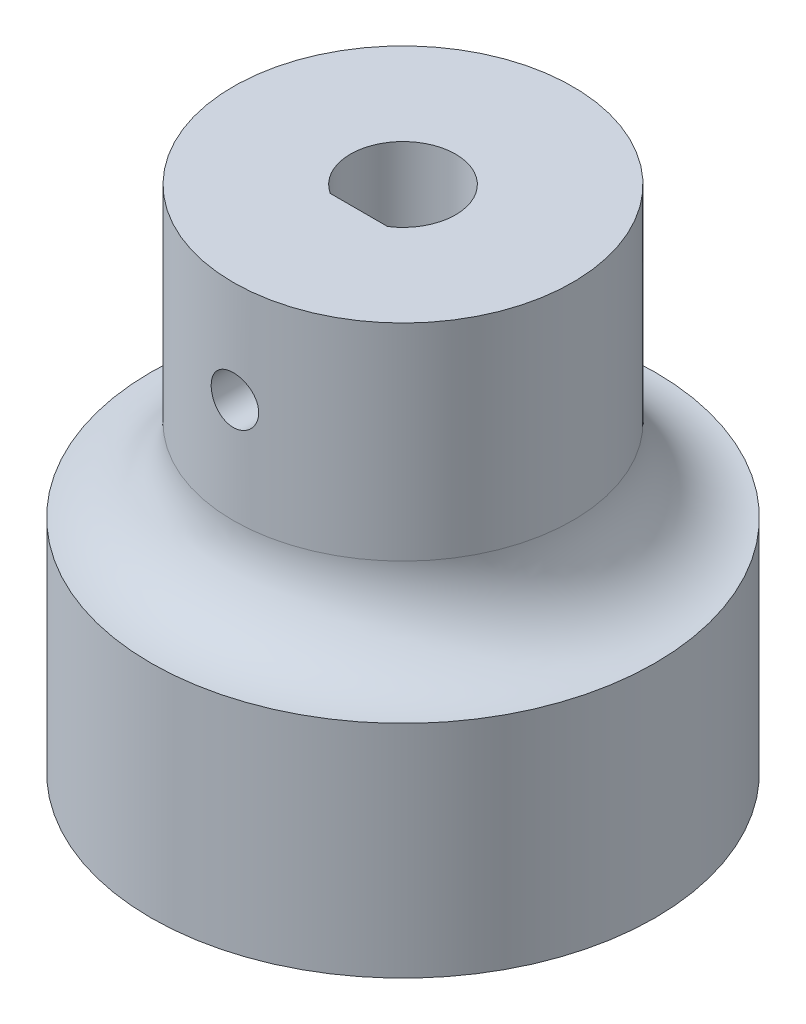
from build123d import *

# Parameters (mm, degrees)
SKETCH_1_R          = 14.85
EXTRUDE_1_DEPTH     = 13
SKETCH_2_R          = 10
EXTRUDE_2_DEPTH     = 17
CUT_EXTRUDE_1_DEPTH = 12
SKETCH_13_R         = 1.4
CUT_EXTRUDE_2_DEPTH = 13.25


with BuildPart() as part:
    # 스케치1 → 보스-돌출1 (new body)
    with BuildSketch(Plane(origin=(0, 0, 0), x_dir=(1, 0, 0), z_dir=(0, 1, 0))):
        Circle(SKETCH_1_R)
    extrude(amount=EXTRUDE_1_DEPTH)

    # 스케치2 → 보스-돌출2 (add)
    with BuildSketch(Plane(origin=(0, 13, 0), x_dir=(1, 0, 0), z_dir=(0, 1, 0))):
        Circle(SKETCH_2_R)
    extrude(amount=EXTRUDE_2_DEPTH)

    # 스케치4 → 컷-돌출1 (cut)
    with BuildSketch(Plane(origin=(0, 30, 0), x_dir=(1, 0, 0), z_dir=(0, 1, 0))):
        with BuildLine():
            Line((-1.688194302, -2.6), (1.688194302, -2.6))
            ThreePointArc((1.688194302, -2.6), (0, 3.1), (-1.688194302, -2.6))
        make_face()
    extrude(amount=-CUT_EXTRUDE_1_DEPTH, mode=Mode.SUBTRACT)

    # 스케치13 → 컷-돌출2 (cut, through all)
    with BuildSketch(Plane(origin=(0, 0, 2.6), x_dir=(-1, 0, 0), z_dir=(0, 0, -1))):
        with Locations((0, 24)):
            Circle(SKETCH_13_R)
    extrude(amount=-CUT_EXTRUDE_2_DEPTH, mode=Mode.SUBTRACT)

    # 스케치3 → 회전1 (revolve)
    with BuildSketch(Plane(origin=(0, 0, 0), x_dir=(0, 0, -1), z_dir=(1, 0, 0))):
        with BuildLine():
            ThreePointArc((-14.85, 13), (-11.420532111, 14.420532111), (-10, 17.85))
            Line((-10, 17.85), (-10, 13))
            Line((-10, 13), (-14.85, 13))
        make_face()
    revolve(axis=Axis((0, 34.691748642, 0), (0, -1, 0)))


solid = part.part
